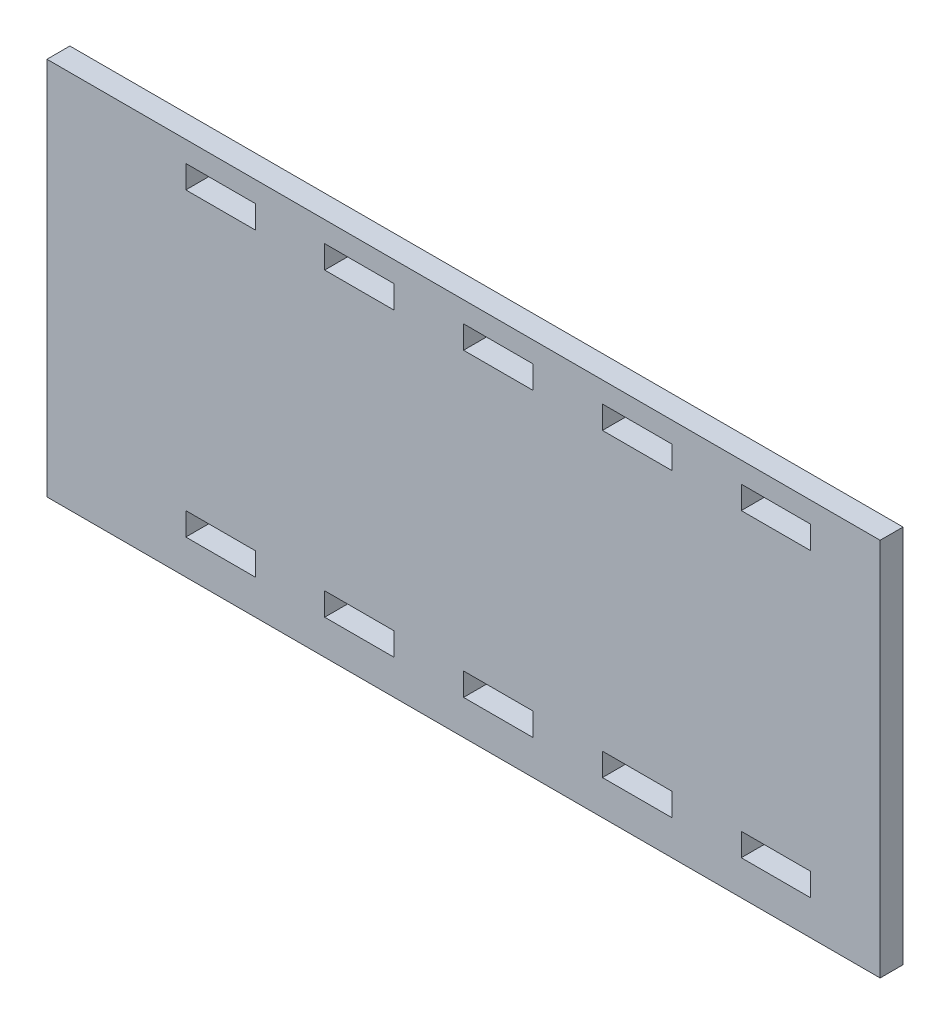
from build123d import *

# Parameters (mm, degrees)
SKETCH1_W           = 120
SKETCH1_H           = 120
BOSS_EXTRUDE1_DEPTH = 3.3
SKETCH2_W           = 10
SKETCH2_H           = 3.3
CUT_EXTRUDE1_DEPTH  = 3.3
LPATTERN1_COUNT     = 5
LPATTERN1_PITCH     = 20
SKETCH3_W           = 120
SKETCH3_H           = 30.4
CUT_EXTRUDE2_DEPTH  = 3.3
SKETCH4_W           = 120
SKETCH4_H           = 3.3
CUT_EXTRUDE3_DEPTH  = 35


with BuildPart() as part:
    # Sketch1 → Boss-Extrude1 (new body)
    with BuildSketch(Plane.XY):
        Rectangle(SKETCH1_W, SKETCH1_H)
    extrude(amount=BOSS_EXTRUDE1_DEPTH)

    # Sketch2 → Cut-Extrude1 (cut)
    with BuildSketch(Plane.XY.offset(3.3)):
        with Locations((45, -18.35)):
            Rectangle(SKETCH2_W, SKETCH2_H)
        with Locations((45, 24.95)):
            Rectangle(SKETCH2_W, SKETCH2_H)
    cut_extrude1 = extrude(amount=-CUT_EXTRUDE1_DEPTH, mode=Mode.SUBTRACT)

    # LPattern1: Cut-Extrude1 ×5
    with Locations(*[(-i * LPATTERN1_PITCH, 0, 0) for i in range(1, LPATTERN1_COUNT)]):
        add(cut_extrude1, mode=Mode.SUBTRACT)

    # Sketch3 → Cut-Extrude2 (cut)
    with BuildSketch(Plane(origin=(0, 0, 0), x_dir=(-1, 0, 0), z_dir=(0, 0, -1))):
        with Locations((0, 44.8)):
            Rectangle(SKETCH3_W, SKETCH3_H)
    extrude(amount=-CUT_EXTRUDE2_DEPTH, mode=Mode.SUBTRACT)

    # Sketch4 → Cut-Extrude3 (cut)
    with BuildSketch(Plane.XZ.offset(60)):
        with Locations((0, 1.65)):
            Rectangle(SKETCH4_W, SKETCH4_H)
    extrude(amount=-CUT_EXTRUDE3_DEPTH, mode=Mode.SUBTRACT)


solid = part.part
